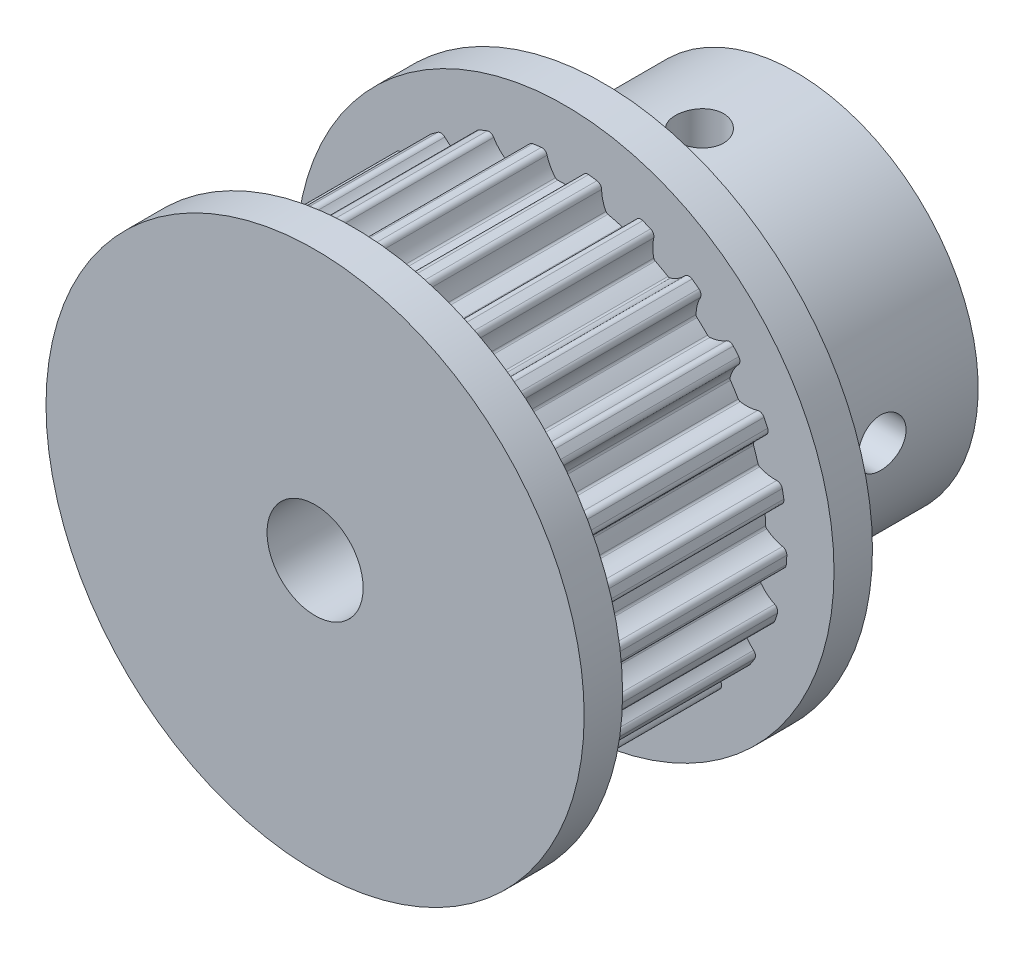
from build123d import *

# Parameters (mm, degrees)
SKETCH_1_R               = 11.555
EXTRUDE_1_DEPTH          = 5.5
CUT_EXTRUDE_START        = -12
CUT_EXTRUDE_1_DEPTH      = 13
PATTERN_CIRCULAR_1_COUNT = 25
SKETCH_3_R               = 14
EXTRUDE_2_DEPTH          = 2
SKETCH_5_R               = 9.5
EXTRUDE_3_DEPTH          = 10
SKETCH_4_R               = 2.5
CUT_EXTRUDE_2_DEPTH      = 26
SKETCH_7_W               = 1.25
SKETCH_7_H               = 14
PATTERN_CIRCULAR_2_COUNT = 2
PATTERN_CIRCULAR_2_ANGLE = 90


with BuildPart() as part:
    # 草圖1 → 填料-伸長1 (new body, symmetric)
    with BuildSketch(Plane.XY):
        Circle(SKETCH_1_R)
    extrude(amount=EXTRUDE_1_DEPTH, both=True)

    # 草圖2 → 除料-伸長1 (cut)
    with BuildSketch(Plane.XY.offset(5.5).offset(CUT_EXTRUDE_START)):
        with BuildLine():
            Line((-63.579258929, 4.819686866), (-1.229056114, 11.489449337))
            ThreePointArc((-1.229056114, 11.489449337), (-1.041654025, 11.442459526), (-0.929297371, 11.28528584))
            ThreePointArc((-0.929297371, 11.28528584), (-0.757654953, 10.86109082), (-0.492996072, 10.487783692))
            ThreePointArc((-0.492996072, 10.487783692), (-0.440050692, 10.450027343), (-0.376101529, 10.438226508))
            ThreePointArc((-0.376101529, 10.438226508), (0, 10.445), (0.376101529, 10.438226508))
            ThreePointArc((0.376101529, 10.438226508), (0.440050692, 10.450027343), (0.492996072, 10.487783692))
            ThreePointArc((0.492996072, 10.487783692), (0.757654953, 10.86109082), (0.929297371, 11.28528584))
            ThreePointArc((0.929297371, 11.28528584), (1.041654025, 11.442459526), (1.229056114, 11.489449337))
            Line((1.229056114, 11.489449337), (63.579258929, 4.819686866))
            Line((63.579258929, 4.819686866), (63.579258929, 130.231544717))
            Line((63.579258929, 130.231544717), (-63.579258929, 130.231544717))
            Line((-63.579258929, 130.231544717), (-63.579258929, 4.819686866))
        make_face()
    cut_extrude_1 = extrude(amount=CUT_EXTRUDE_1_DEPTH, mode=Mode.SUBTRACT)

    # 環狀複製排列1: 除料-伸長1 ×25 about axis
    pattern_circular_1_axis = Axis((0, 0, 5.5), (0, 0, 1))
    for i in range(1, PATTERN_CIRCULAR_1_COUNT):
        add(cut_extrude_1.rotate(pattern_circular_1_axis, i * 360 / PATTERN_CIRCULAR_1_COUNT), mode=Mode.SUBTRACT)

    # 草圖3 → 填料-伸長2 (add)
    with BuildSketch(Plane.XY.offset(5.5)):
        Circle(SKETCH_3_R)
    extrude_2 = extrude(amount=EXTRUDE_2_DEPTH)

    # 鏡射1: 填料-伸長2 across plane
    add(extrude_2.mirror(Plane.XY))

    # 草圖5 → 填料-伸長3 (add)
    with BuildSketch(Plane(origin=(0, 0, -7.5), x_dir=(-1, 0, 0), z_dir=(0, 0, -1))):
        Circle(SKETCH_5_R)
    extrude(amount=EXTRUDE_3_DEPTH)

    # 草圖4 → 除料-伸長2 (cut, through all)
    with BuildSketch(Plane.XY.offset(7.5)):
        Circle(SKETCH_4_R)
    extrude(amount=-CUT_EXTRUDE_2_DEPTH, mode=Mode.SUBTRACT)

    # 草圖7 → M3x0.5 螺紋孔1 (revolve, cut)
    with BuildSketch(Plane(origin=(0, 0, -12.5), x_dir=(0, 0, -1), z_dir=(1, 0, 0))):
        with Locations((0.625, 7)):
            Rectangle(SKETCH_7_W, SKETCH_7_H)
    m3x0_5_1 = revolve(axis=Axis((0, -6.35, -12.5), (0, 1, 0)), mode=Mode.SUBTRACT)

    # 環狀複製排列2: M3x0.5 螺紋孔1 ×2 about axis
    pattern_circular_2_axis = Axis((0, 0, -17.5), (0, 0, -1))
    for i in range(1, PATTERN_CIRCULAR_2_COUNT):
        add(m3x0_5_1.rotate(pattern_circular_2_axis, i * PATTERN_CIRCULAR_2_ANGLE / (PATTERN_CIRCULAR_2_COUNT - 1)), mode=Mode.SUBTRACT)


solid = part.part
